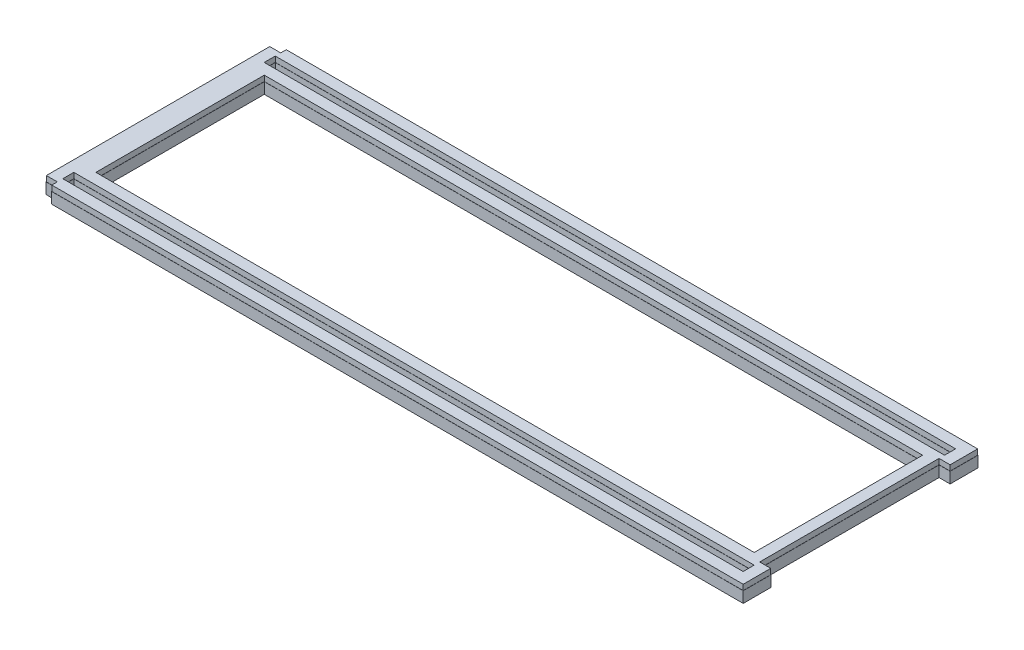
from build123d import *

# Parameters (mm, degrees)
SKETCH1_W           = 393.6492
SKETCH1_H           = 6.4008
SKETCH1_W_2         = 380.8984
SKETCH1_H_2         = 97.44075
BOSS_EXTRUDE1_DEPTH = 3.175
SKETCH5_W           = 393.446
SKETCH5_H           = 6.1976
SKETCH5_W_2         = 380.6952
SKETCH5_H_2         = 97.23755
BOSS_EXTRUDE4_DEPTH = 6.35


with BuildPart() as part:
    # Sketch1 → Boss-Extrude1 (new body)
    with BuildSketch(Plane(origin=(0, 0, 0), x_dir=(1, 0, 0), z_dir=(0, 1, 0))):
        Polygon((-203.2, 64.620775), (-203.2, -64.620775), (-196.85, -64.620775), (-196.85, -67.821175), (203.2, -67.821175), (203.2, -51.895375), (196.7992, -51.895375), (196.7992, 51.895375), (203.2, 51.895375), (203.2, 67.821175), (-196.85, 67.821175), (-196.85, 64.620775), align=None)
        with Locations((-0.0254, 58.270775)):
            Rectangle(SKETCH1_W, SKETCH1_H, mode=Mode.SUBTRACT)
        with Locations((-0.0254, -58.270775)):
            Rectangle(SKETCH1_W, SKETCH1_H, mode=Mode.SUBTRACT)
        Rectangle(SKETCH1_W_2, SKETCH1_H_2, mode=Mode.SUBTRACT)
    extrude(amount=BOSS_EXTRUDE1_DEPTH)

    # Sketch5 → Boss-Extrude4 (add)
    with BuildSketch(Plane(origin=(0, 0, 0), x_dir=(-1, 0, 0), z_dir=(0, -1, 0))):
        Polygon((-203.3016, -51.793775), (-203.3016, -67.922775), (196.9516, -67.922775), (196.9516, -64.722375), (203.3016, -64.722375), (203.3016, 64.722375), (196.9516, 64.722375), (196.9516, 67.922775), (-203.3016, 67.922775), (-203.3016, 51.793775), (-196.9008, 51.793775), (-196.9008, -51.793775), align=None)
        with Locations((0.0254, 58.270775)):
            Rectangle(SKETCH5_W, SKETCH5_H, mode=Mode.SUBTRACT)
        Rectangle(SKETCH5_W_2, SKETCH5_H_2, mode=Mode.SUBTRACT)
        with Locations((0.0254, -58.270775)):
            Rectangle(SKETCH5_W, SKETCH5_H, mode=Mode.SUBTRACT)
    extrude(amount=BOSS_EXTRUDE4_DEPTH)


solid = part.part
